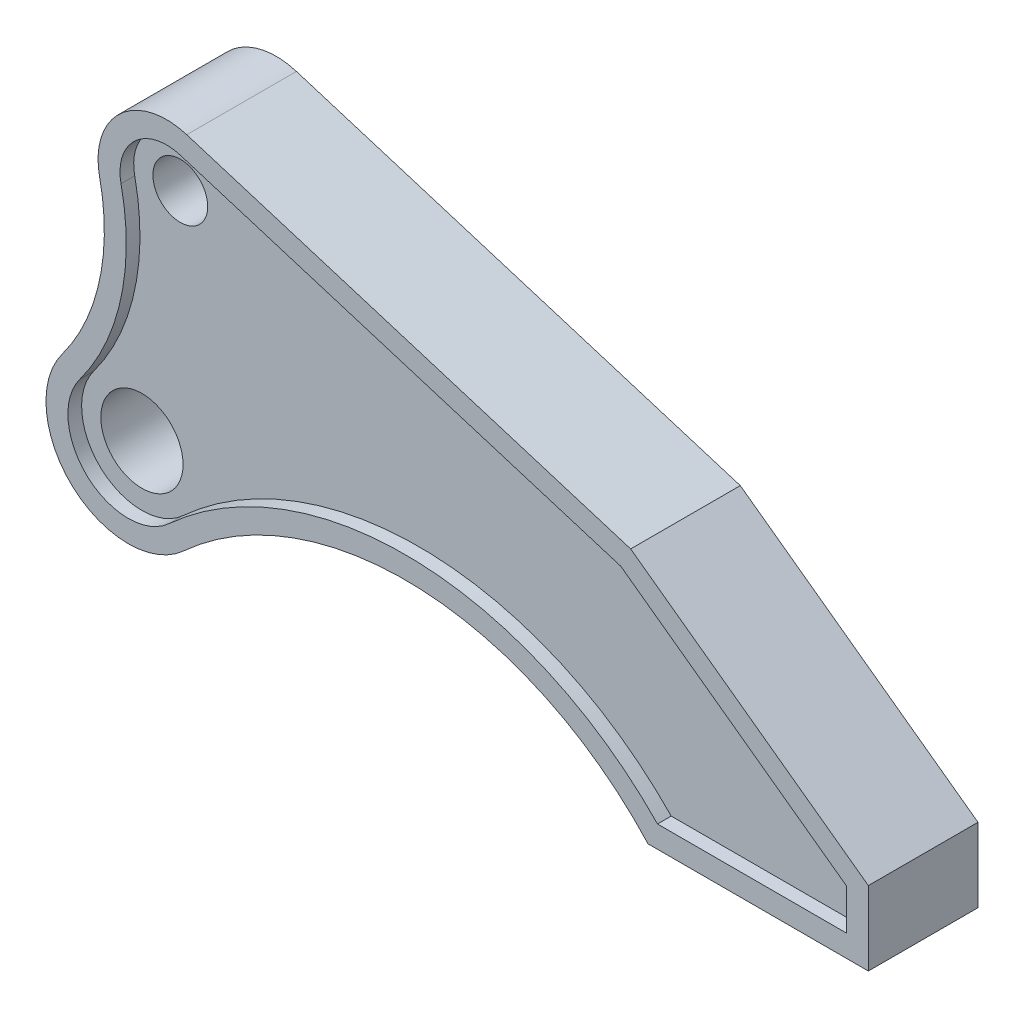
from build123d import *

# Parameters (mm, degrees)
SKETCH2_R           = 30
SKETCH2_R_2         = 25
BOSS_EXTRUDE1_DEPTH = 15
BOSS_EXTRUDE2_DEPTH = 20
SKETCH5_R           = 10
SKETCH5_R_2         = 15
CUT_EXTRUDE2_DEPTH  = 40


with BuildPart() as part:
    # Sketch2 → Boss-Extrude1 (new body, symmetric)
    with BuildSketch(Plane.XY):
        with BuildLine():
            Line((183.28793901, 60), (21.361321264, 109.891650199))
            ThreePointArc((21.361321264, 109.891650199), (34.112595949, 100.848686279), (39, 86))
            ThreePointArc((39, 86), (16.637488364, 61.139516193), (-10.44349241, 80.754461058))
            ThreePointArc((-10.44349241, 80.754461058), (-10.481072196, 47.848151082), (-24.085330203, 17.885660989))
            ThreePointArc((-24.085330203, 17.885660989), (9.419131964, 28.482976548), (30, 0))
            ThreePointArc((30, 0), (27.440845468, -12.124355653), (20.2, -22.180171325))
            ThreePointArc((20.2, -22.180171325), (106.532601106, 8.971535214), (189.628727834, -30))
            Line((189.628727834, -30), (270, -30))
            Line((270, -30), (270, -3))
            Line((270, -3), (183.28793901, 60))
        make_face()
        Circle(SKETCH2_R)
        with Locations((14, 86)):
            Circle(SKETCH2_R_2)
    extrude(amount=BOSS_EXTRUDE1_DEPTH, both=True)

    # Sketch4 → Boss-Extrude2 (add, symmetric)
    with BuildSketch(Plane.XY):
        with BuildLine():
            Line((189.628727834, -30), (270, -30))
            Line((270, -30), (270, -3))
            Line((270, -3), (183.28793901, 60))
            Line((183.28793901, 60), (21.361321264, 109.891650199))
            ThreePointArc((21.361321264, 109.891650199), (-2.887690503, 104.433825145), (-10.44349241, 80.754461058))
            ThreePointArc((-10.44349241, 80.754461058), (-10.481072196, 47.848151082), (-24.085330203, 17.885660989))
            ThreePointArc((-24.085330203, 17.885660989), (-20.126889413, -22.246535068), (20.2, -22.180171325))
            ThreePointArc((20.2, -22.180171325), (106.532601106, 8.971535214), (189.628727834, -30))
        make_face()
        with BuildLine():
            Line((193.090377844, -22), (262, -22))
            Line((262, -22), (262, -7.076203596))
            Line((262, -7.076203596), (179.661480345, 52.746232627))
            Line((179.661480345, 52.746232627), (19.00569846, 102.246322136))
            ThreePointArc((19.00569846, 102.246322136), (2.516370458, 98.535001099), (-2.621574839, 82.43303352))
            ThreePointArc((-2.621574839, 82.43303352), (-2.663008962, 46.151717392), (-17.662575482, 13.116151392))
            ThreePointArc((-17.662575482, 13.116151392), (-14.759718903, -16.314125717), (14.813333333, -16.265458972))
            ThreePointArc((14.813333333, -16.265458972), (105.1151782, 17.032975134), (193.090377844, -22))
        make_face(mode=Mode.SUBTRACT)
    extrude(amount=BOSS_EXTRUDE2_DEPTH, both=True)

    # Sketch5 → Cut-Extrude2 (cut)
    with BuildSketch(Plane.XY.offset(15)):
        with Locations((14, 86)):
            Circle(SKETCH5_R)
        Circle(SKETCH5_R_2)
    extrude(amount=-CUT_EXTRUDE2_DEPTH, mode=Mode.SUBTRACT)


solid = part.part
